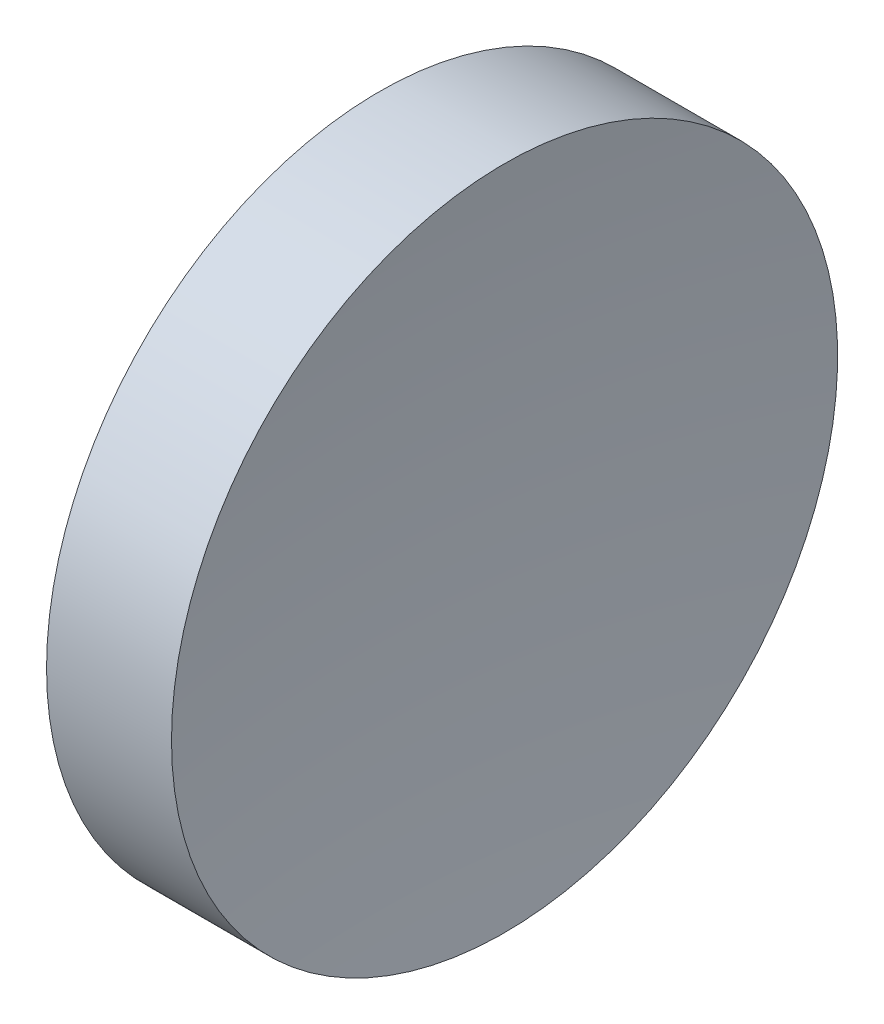
from build123d import *


with BuildPart() as part:
    # 草图1 → 旋转1 (revolve)
    with BuildSketch(Plane(origin=(0, 0, 0), x_dir=(1, 0, 0), z_dir=(0, 1, 0)), mode=Mode.PRIVATE) as revolve_1_sk:
        with BuildLine():
            Line((0, 0), (7.91, 0))
            ThreePointArc((7.91, 0), (8.315274769, 12.725787202), (9.529456599, 25.4))
            Line((9.529456599, 25.4), (0, 25.4))
            Line((0, 25.4), (0, 0))
        make_face()
    revolve(revolve_1_sk.sketch.rotate(Axis((0, 0, 0), (1, 0, 0)), 180), axis=Axis((0, 0, 0), (1, 0, 0)))  # turned: the seam where the file's is


solid = part.part
